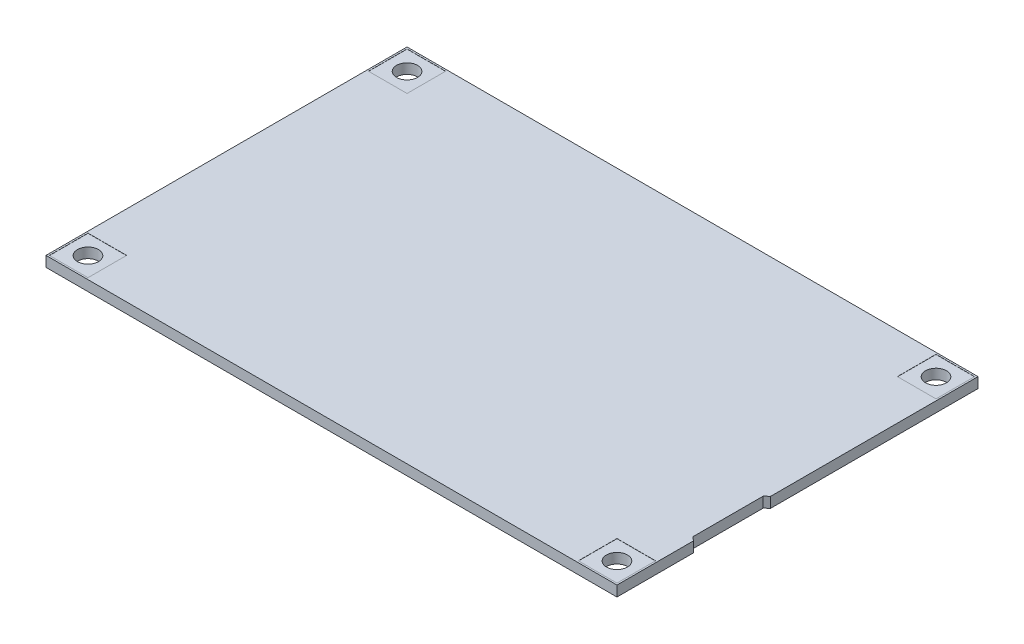
from build123d import *

# Parameters (mm, degrees)
SKETCH1_R           = 1.5875
BOSS_EXTRUDE1_DEPTH = 1.5748
SKETCH2_W           = 5.842
SKETCH2_H           = 5.842
CUT_EXTRUDE1_DEPTH  = 0.0254
CUT_EXTRUDE2_START  = -1.5748
SKETCH2_2_W         = 5.842
SKETCH2_2_H         = 5.842
CUT_EXTRUDE2_DEPTH  = 0.0254


with BuildPart() as part:
    # Sketch1 → Boss-Extrude1 (new body)
    with BuildSketch(Plane(origin=(0, 0, 0), x_dir=(1, 0, 0), z_dir=(0, 1, 0))):
        Polygon((85.774022, 22.698964), (85.774022, 12.099036), (86.36, 11.557), (86.36, 0), (0, 0), (0, 54.61), (86.36, 54.61), (86.36, 23.241), align=None)
        with Locations((3.175, 51.435)):
            Circle(SKETCH1_R, mode=Mode.SUBTRACT)
        with Locations((3.175, 3.175)):
            Circle(SKETCH1_R, mode=Mode.SUBTRACT)
        with Locations((83.185, 3.175)):
            Circle(SKETCH1_R, mode=Mode.SUBTRACT)
        with Locations((83.185, 51.435)):
            Circle(SKETCH1_R, mode=Mode.SUBTRACT)
    extrude(amount=BOSS_EXTRUDE1_DEPTH)

    # Sketch2 → Cut-Extrude1 (cut)
    with BuildSketch(Plane(origin=(0, 1.5748, 0), x_dir=(1, 0, 0), z_dir=(0, 1, 0))):
        with Locations((3.175, 51.435)):
            Rectangle(SKETCH2_W, SKETCH2_H)
        with Locations((3.175, 3.175)):
            Rectangle(SKETCH2_W, SKETCH2_H)
        with Locations((83.185, 3.175)):
            Rectangle(SKETCH2_W, SKETCH2_H)
        with Locations((83.185, 51.435)):
            Rectangle(SKETCH2_W, SKETCH2_H)
    extrude(amount=-CUT_EXTRUDE1_DEPTH, mode=Mode.SUBTRACT)

    # Sketch2_2 → Cut-Extrude2 (cut)
    with BuildSketch(Plane(origin=(0, 1.5748, 0), x_dir=(1, 0, 0), z_dir=(0, 1, 0)).offset(CUT_EXTRUDE2_START)):
        with Locations((3.175, 51.435)):
            Rectangle(SKETCH2_2_W, SKETCH2_2_H)
        with Locations((3.175, 3.175)):
            Rectangle(SKETCH2_2_W, SKETCH2_2_H)
        with Locations((83.185, 3.175)):
            Rectangle(SKETCH2_2_W, SKETCH2_2_H)
        with Locations((83.185, 51.435)):
            Rectangle(SKETCH2_2_W, SKETCH2_2_H)
    extrude(amount=CUT_EXTRUDE2_DEPTH, mode=Mode.SUBTRACT)


solid = part.part
